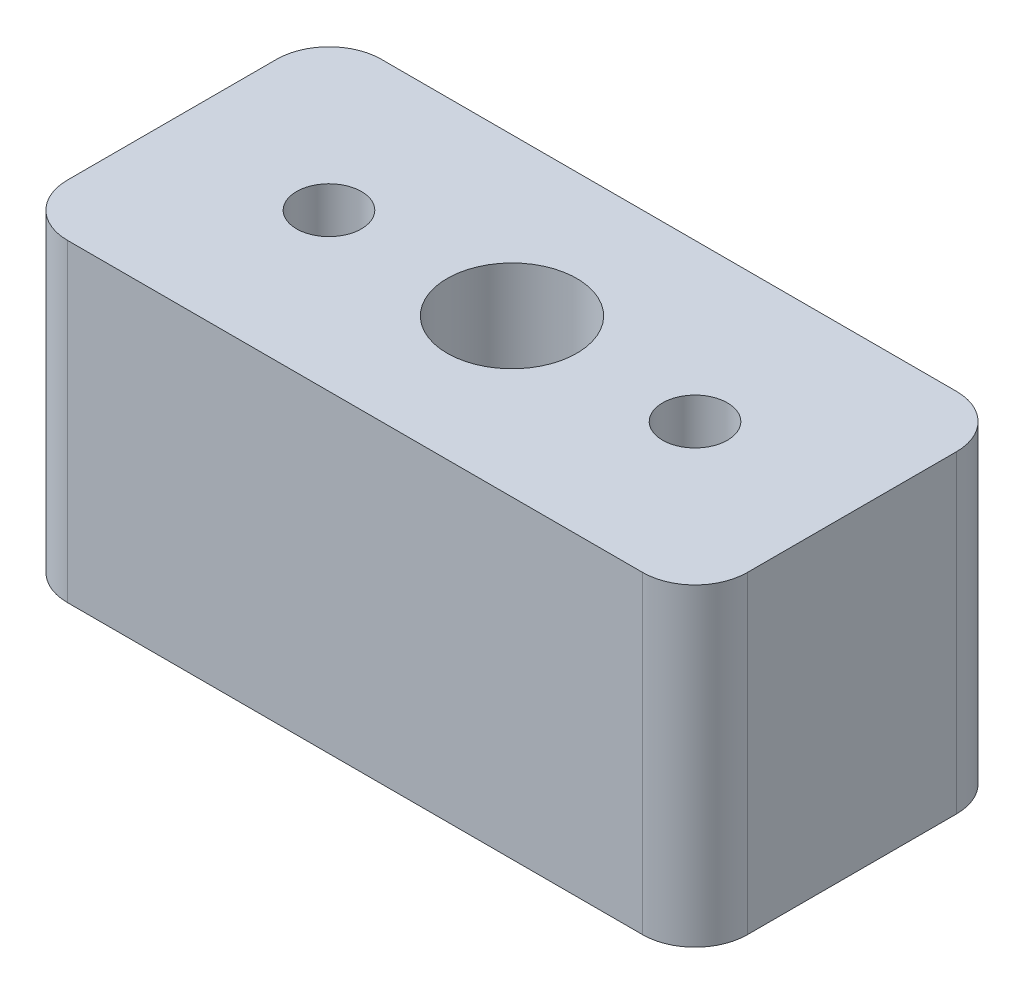
from build123d import *

# Parameters (mm, degrees)
SKETCH1_W           = 6.5
SKETCH1_H           = 3
SKETCH1_R           = 0.31
SKETCH1_R_2         = 0.62
BOSS_EXTRUDE1_DEPTH = 3
FILLET1_R           = 0.5


with BuildPart() as part:
    # Sketch1 → Boss-Extrude1 (new body)
    with BuildSketch(Plane(origin=(0, 0, 0), x_dir=(1, 0, 0), z_dir=(0, 1, 0))):
        Rectangle(SKETCH1_W, SKETCH1_H)
        with Locations((-1.75, 0)):
            Circle(SKETCH1_R, mode=Mode.SUBTRACT)
        Circle(SKETCH1_R_2, mode=Mode.SUBTRACT)
        with Locations((1.75, 0)):
            Circle(SKETCH1_R, mode=Mode.SUBTRACT)
    extrude(amount=BOSS_EXTRUDE1_DEPTH)

    # Fillet1
    fillet1_edges = [part.edges().sort_by_distance(p)[0] for p in [
        (-3.25, 1.5, -1.5),
        (3.25, 1.5, -1.5),
        (3.25, 1.5, 1.5),
        (-3.25, 1.5, 1.5),
    ]]
    fillet(fillet1_edges, radius=FILLET1_R)


solid = part.part
